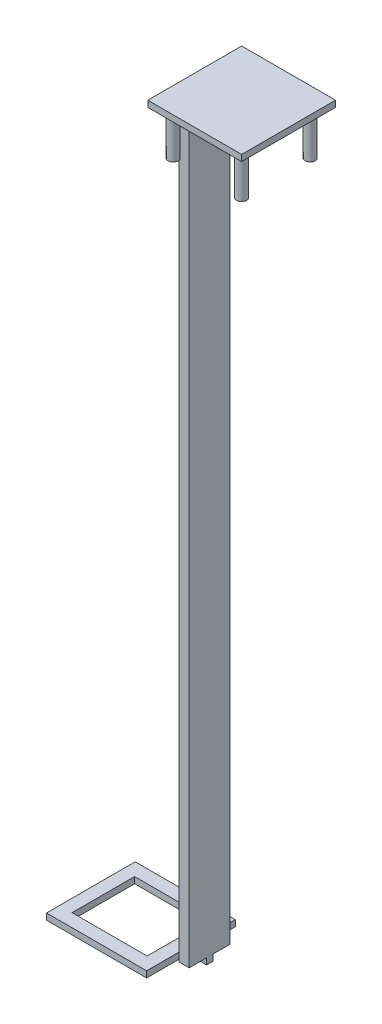
from build123d import *

# Parameters (mm, degrees)
BOSS_EXTRUDE1_DEPTH = 152.4
SKETCH2_W           = 19.05
SKETCH2_H           = 19.05
BOSS_EXTRUDE2_DEPTH = 1.27
SKETCH3_R           = 1.016
BOSS_EXTRUDE3_DEPTH = 8.89
BOSS_EXTRUDE4_DEPTH = 1.27
SKETCH5_W           = 15.24
SKETCH5_H           = 12.7
CUT_EXTRUDE1_DEPTH  = 2.27


with BuildPart() as part:
    # Sketch1 → Boss-Extrude1 (new body)
    with BuildSketch(Plane(origin=(0, 0, 0), x_dir=(1, 0, 0), z_dir=(0, 1, 0))):
        Polygon((0.1397, 7.023481), (-0.8763, 7.023481), (-0.8763, 1.305306), (0.1397, 1.305306), (0.1397, 0), (2.1717, 0), (2.1717, 8.328787), (0.1397, 8.328787), align=None)
    extrude(amount=BOSS_EXTRUDE1_DEPTH)

    # Sketch2 → Boss-Extrude2 (add)
    with BuildSketch(Plane(origin=(0, 152.4, 0), x_dir=(1, 0, 0), z_dir=(0, 1, 0))):
        with Locations((8.6487, 4.1643935)):
            Rectangle(SKETCH2_W, SKETCH2_H)
    extrude(amount=BOSS_EXTRUDE2_DEPTH)

    # Sketch3 → Boss-Extrude3 (add)
    with BuildSketch(Plane.XZ.offset(-152.4)):
        with Locations((15.602834065, 2.789740565)):
            Circle(SKETCH3_R)
        with Locations((15.602834065, -11.118527565)):
            Circle(SKETCH3_R)
        with Locations((1.694565935, -11.118527565)):
            Circle(SKETCH3_R)
        with Locations((1.694565935, 2.789740565)):
            Circle(SKETCH3_R)
    extrude(amount=BOSS_EXTRUDE3_DEPTH)

    # Sketch4 → Boss-Extrude4 (add)
    with BuildSketch(Plane.XZ):
        Polygon((-21.9583, 4.8356065), (-1.6383, 4.8356065), (-1.6383, -3.5293935), (2.1717, -3.5293935), (2.1717, -4.7993935), (-1.6383, -4.7993935), (-1.6383, -13.1643935), (-21.9583, -13.1643935), align=None)
    extrude(amount=BOSS_EXTRUDE4_DEPTH)

    # Sketch5 → Cut-Extrude1 (cut, through all)
    with BuildSketch(Plane(origin=(0, 0, 0), x_dir=(1, 0, 0), z_dir=(0, 1, 0))):
        with Locations((-11.7983, 4.1643935)):
            Rectangle(SKETCH5_W, SKETCH5_H)
    extrude(amount=-CUT_EXTRUDE1_DEPTH, mode=Mode.SUBTRACT)


solid = part.part
